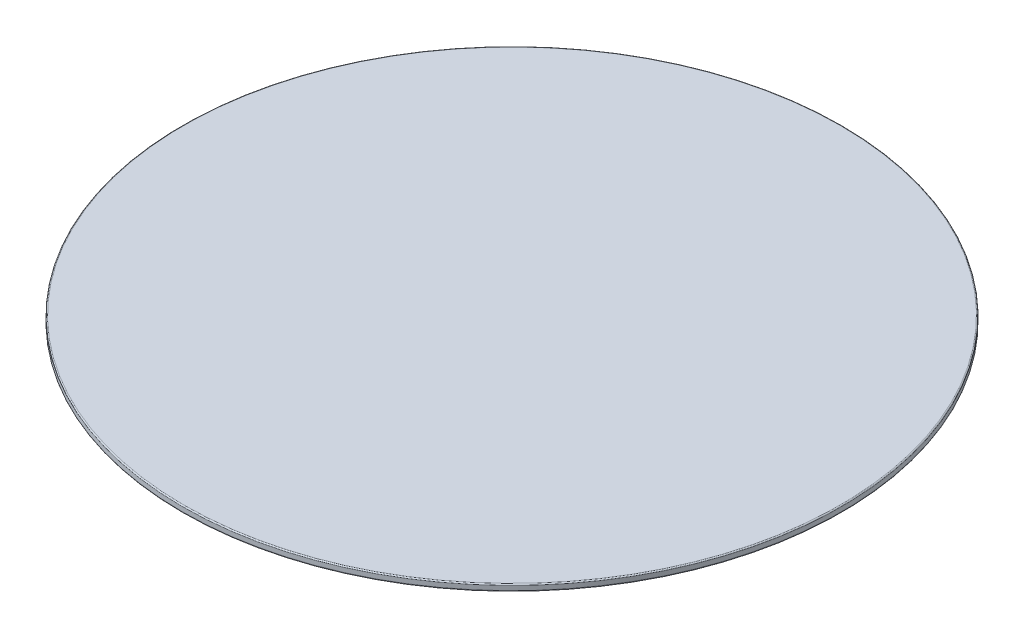
from build123d import *

# Parameters (mm, degrees)
SKETCH1_R           = 150
BOSS_EXTRUDE1_DEPTH = 3
FILLET1_R           = 0.5


with BuildPart() as part:
    # Sketch1 → Boss-Extrude1 (new body)
    with BuildSketch(Plane(origin=(0, 0, 0), x_dir=(1, 0, 0), z_dir=(0, 1, 0))):
        Circle(SKETCH1_R)
    extrude(amount=BOSS_EXTRUDE1_DEPTH)

    # Fillet1
    fillet1_edges = [part.edges().sort_by_distance(p)[0] for p in [
        (-150, 0, 0),
        (-150, 3, 0),
    ]]
    fillet(fillet1_edges, radius=FILLET1_R)


solid = part.part
